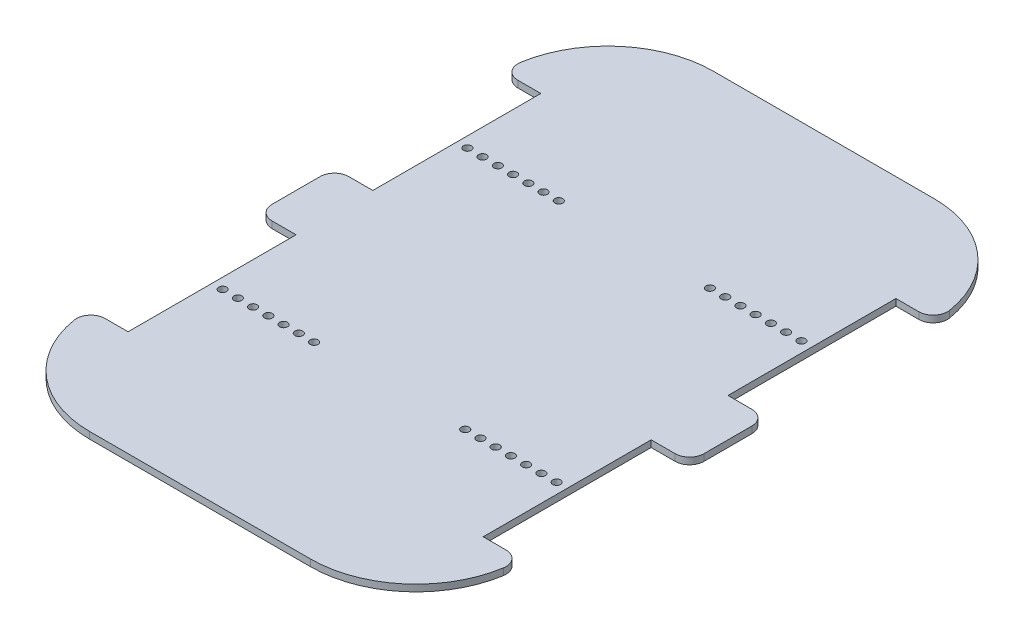
from build123d import *

# Parameters (mm, degrees)
BOSS_EXTRUDE4_DEPTH = 2.8
SKETCH5_R           = 1.65
CUT_EXTRUDE1_DEPTH  = 3.8


with BuildPart() as part:
    # Sketch2 → Boss-Extrude4 (new body)
    with BuildSketch(Plane(origin=(0, 0, 0), x_dir=(1, 0, 0), z_dir=(0, 1, 0))):
        with BuildLine():
            Line((46, -130), (-46, -130))
            ThreePointArc((-46, -130), (-74.550970119, -119.478980051), (-89.448061775, -92.947368421))
            ThreePointArc((-89.448061775, -92.947368421), (-88.08864154, -88.106685893), (-83.523326079, -86))
            Line((-83.523326079, -86), (-74, -86))
            Line((-74, -86), (-74, -16))
            Line((-74, -16), (-84, -16))
            ThreePointArc((-84, -16), (-88.242640687, -14.242640687), (-90, -10))
            Line((-90, -10), (-90, 10))
            ThreePointArc((-90, 10), (-88.242640687, 14.242640687), (-84, 16))
            Line((-84, 16), (-74, 16))
            Line((-74, 16), (-74, 86))
            Line((-74, 86), (-83.523326079, 86))
            ThreePointArc((-83.523326079, 86), (-88.08864154, 88.106685893), (-89.448061775, 92.947368421))
            ThreePointArc((-89.448061775, 92.947368421), (-74.550970119, 119.478980051), (-46, 130))
            Line((-46, 130), (46, 130))
            ThreePointArc((46, 130), (74.550970119, 119.478980051), (89.448061775, 92.947368421))
            ThreePointArc((89.448061775, 92.947368421), (88.08864154, 88.106685893), (83.523326079, 86))
            Line((83.523326079, 86), (74, 86))
            Line((74, 86), (74, 16))
            Line((74, 16), (84, 16))
            ThreePointArc((84, 16), (88.242640687, 14.242640687), (90, 10))
            Line((90, 10), (90, -10))
            ThreePointArc((90, -10), (88.242640687, -14.242640687), (84, -16))
            Line((84, -16), (74, -16))
            Line((74, -16), (74, -86))
            Line((74, -86), (83.523326079, -86))
            ThreePointArc((83.523326079, -86), (88.08864154, -88.106685893), (89.448061775, -92.947368421))
            ThreePointArc((89.448061775, -92.947368421), (74.550970119, -119.478980051), (46, -130))
        make_face()
    extrude(amount=BOSS_EXTRUDE4_DEPTH)

    # Sketch5 → Cut-Extrude1 (cut, through all)
    with BuildSketch(Plane(origin=(0, 2.8, 0), x_dir=(1, 0, 0), z_dir=(0, 1, 0))):
        with Locations((-69.6, -51)):
            Circle(SKETCH5_R)
        with Locations((-63.25, -51)):
            Circle(SKETCH5_R)
        with Locations((-56.9, -51)):
            Circle(SKETCH5_R)
        with Locations((-50.55, -51)):
            Circle(SKETCH5_R)
        with Locations((-44.2, -51)):
            Circle(SKETCH5_R)
        with Locations((-37.85, -51)):
            Circle(SKETCH5_R)
        with Locations((-31.5, -51)):
            Circle(SKETCH5_R)
        with Locations((31.5, -51)):
            Circle(SKETCH5_R)
        with Locations((37.85, -51)):
            Circle(SKETCH5_R)
        with Locations((44.2, -51)):
            Circle(SKETCH5_R)
        with Locations((50.55, -51)):
            Circle(SKETCH5_R)
        with Locations((56.9, -51)):
            Circle(SKETCH5_R)
        with Locations((63.25, -51)):
            Circle(SKETCH5_R)
        with Locations((69.6, -51)):
            Circle(SKETCH5_R)
        with Locations((69.6, 51)):
            Circle(SKETCH5_R)
        with Locations((63.25, 51)):
            Circle(SKETCH5_R)
        with Locations((56.9, 51)):
            Circle(SKETCH5_R)
        with Locations((50.55, 51)):
            Circle(SKETCH5_R)
        with Locations((44.2, 51)):
            Circle(SKETCH5_R)
        with Locations((37.85, 51)):
            Circle(SKETCH5_R)
        with Locations((31.5, 51)):
            Circle(SKETCH5_R)
        with Locations((-31.5, 51)):
            Circle(SKETCH5_R)
        with Locations((-37.85, 51)):
            Circle(SKETCH5_R)
        with Locations((-44.2, 51)):
            Circle(SKETCH5_R)
        with Locations((-50.55, 51)):
            Circle(SKETCH5_R)
        with Locations((-56.9, 51)):
            Circle(SKETCH5_R)
        with Locations((-63.25, 51)):
            Circle(SKETCH5_R)
        with Locations((-69.6, 51)):
            Circle(SKETCH5_R)
    extrude(amount=-CUT_EXTRUDE1_DEPTH, mode=Mode.SUBTRACT)


solid = part.part
